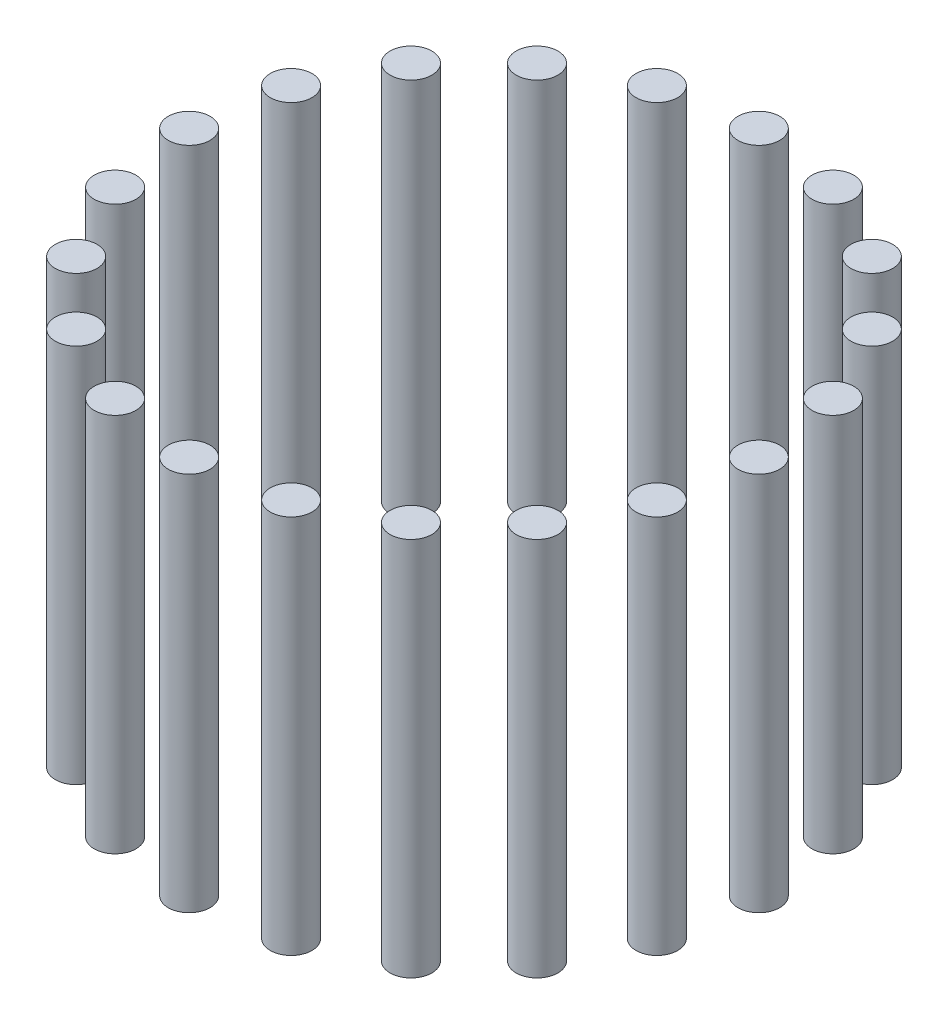
from build123d import *

# Parameters (mm, degrees)
SKETCH1_R              = 5.5
BOSS_EXTRUDE1_DEPTH    = 100
BOSS_EXTRUDE1_2_DEPTH  = 100
BOSS_EXTRUDE1_3_DEPTH  = 100
BOSS_EXTRUDE1_4_DEPTH  = 100
BOSS_EXTRUDE1_5_DEPTH  = 100
BOSS_EXTRUDE1_6_DEPTH  = 100
BOSS_EXTRUDE1_7_DEPTH  = 100
BOSS_EXTRUDE1_8_DEPTH  = 100
BOSS_EXTRUDE1_9_DEPTH  = 100
BOSS_EXTRUDE1_10_DEPTH = 100
BOSS_EXTRUDE1_11_DEPTH = 100
BOSS_EXTRUDE1_12_DEPTH = 100
BOSS_EXTRUDE1_13_DEPTH = 100
BOSS_EXTRUDE1_14_DEPTH = 100
BOSS_EXTRUDE1_15_DEPTH = 100
BOSS_EXTRUDE1_16_DEPTH = 100
BOSS_EXTRUDE1_17_DEPTH = 100
BOSS_EXTRUDE1_18_DEPTH = 100
BOSS_EXTRUDE1_19_DEPTH = 100
BOSS_EXTRUDE1_20_DEPTH = 100


with BuildPart() as part:
    # Sketch1 → Boss-Extrude1 (new body)
    with BuildSketch(Plane(origin=(0, 0, 0), x_dir=(1, 0, 0), z_dir=(0, 1, 0))):
        with Locations((0, 75)):
            Circle(SKETCH1_R)
    extrude(amount=BOSS_EXTRUDE1_DEPTH)


with BuildPart() as body_2:
    # Sketch1 → Boss-Extrude1 2 (new body)
    with BuildSketch(Plane(origin=(0, 0, 0), x_dir=(1, 0, 0), z_dir=(0, 1, 0))):
        with Locations((23.176274578, 71.329238722)):
            Circle(SKETCH1_R)
    extrude(amount=BOSS_EXTRUDE1_2_DEPTH)


with BuildPart() as body_3:
    # Sketch1 → Boss-Extrude1 3 (new body)
    with BuildSketch(Plane(origin=(0, 0, 0), x_dir=(1, 0, 0), z_dir=(0, 1, 0))):
        with Locations((44.083893922, 60.676274578)):
            Circle(SKETCH1_R)
    extrude(amount=BOSS_EXTRUDE1_3_DEPTH)


with BuildPart() as body_4:
    # Sketch1 → Boss-Extrude1 4 (new body)
    with BuildSketch(Plane(origin=(0, 0, 0), x_dir=(1, 0, 0), z_dir=(0, 1, 0))):
        with Locations((60.676274578, 44.083893922)):
            Circle(SKETCH1_R)
    extrude(amount=BOSS_EXTRUDE1_4_DEPTH)


with BuildPart() as body_5:
    # Sketch1 → Boss-Extrude1 5 (new body)
    with BuildSketch(Plane(origin=(0, 0, 0), x_dir=(1, 0, 0), z_dir=(0, 1, 0))):
        with Locations((71.329238722, 23.176274578)):
            Circle(SKETCH1_R)
    extrude(amount=BOSS_EXTRUDE1_5_DEPTH)


with BuildPart() as body_6:
    # Sketch1 → Boss-Extrude1 6 (new body)
    with BuildSketch(Plane(origin=(0, 0, 0), x_dir=(1, 0, 0), z_dir=(0, 1, 0))):
        with Locations((75, 0)):
            Circle(SKETCH1_R)
    extrude(amount=BOSS_EXTRUDE1_6_DEPTH)


with BuildPart() as body_7:
    # Sketch1 → Boss-Extrude1 7 (new body)
    with BuildSketch(Plane(origin=(0, 0, 0), x_dir=(1, 0, 0), z_dir=(0, 1, 0))):
        with Locations((71.329238722, -23.176274578)):
            Circle(SKETCH1_R)
    extrude(amount=BOSS_EXTRUDE1_7_DEPTH)


with BuildPart() as body_8:
    # Sketch1 → Boss-Extrude1 8 (new body)
    with BuildSketch(Plane(origin=(0, 0, 0), x_dir=(1, 0, 0), z_dir=(0, 1, 0))):
        with Locations((60.676274578, -44.083893922)):
            Circle(SKETCH1_R)
    extrude(amount=BOSS_EXTRUDE1_8_DEPTH)


with BuildPart() as body_9:
    # Sketch1 → Boss-Extrude1 9 (new body)
    with BuildSketch(Plane(origin=(0, 0, 0), x_dir=(1, 0, 0), z_dir=(0, 1, 0))):
        with Locations((44.083893922, -60.676274578)):
            Circle(SKETCH1_R)
    extrude(amount=BOSS_EXTRUDE1_9_DEPTH)


with BuildPart() as body_10:
    # Sketch1 → Boss-Extrude1 10 (new body)
    with BuildSketch(Plane(origin=(0, 0, 0), x_dir=(1, 0, 0), z_dir=(0, 1, 0))):
        with Locations((23.176274578, -71.329238722)):
            Circle(SKETCH1_R)
    extrude(amount=BOSS_EXTRUDE1_10_DEPTH)


with BuildPart() as body_11:
    # Sketch1 → Boss-Extrude1 11 (new body)
    with BuildSketch(Plane(origin=(0, 0, 0), x_dir=(1, 0, 0), z_dir=(0, 1, 0))):
        with Locations((0, -75)):
            Circle(SKETCH1_R)
    extrude(amount=BOSS_EXTRUDE1_11_DEPTH)


with BuildPart() as body_12:
    # Sketch1 → Boss-Extrude1 12 (new body)
    with BuildSketch(Plane(origin=(0, 0, 0), x_dir=(1, 0, 0), z_dir=(0, 1, 0))):
        with Locations((-23.176274578, -71.329238722)):
            Circle(SKETCH1_R)
    extrude(amount=BOSS_EXTRUDE1_12_DEPTH)


with BuildPart() as body_13:
    # Sketch1 → Boss-Extrude1 13 (new body)
    with BuildSketch(Plane(origin=(0, 0, 0), x_dir=(1, 0, 0), z_dir=(0, 1, 0))):
        with Locations((-44.083893922, -60.676274578)):
            Circle(SKETCH1_R)
    extrude(amount=BOSS_EXTRUDE1_13_DEPTH)


with BuildPart() as body_14:
    # Sketch1 → Boss-Extrude1 14 (new body)
    with BuildSketch(Plane(origin=(0, 0, 0), x_dir=(1, 0, 0), z_dir=(0, 1, 0))):
        with Locations((-60.676274578, -44.083893922)):
            Circle(SKETCH1_R)
    extrude(amount=BOSS_EXTRUDE1_14_DEPTH)


with BuildPart() as body_15:
    # Sketch1 → Boss-Extrude1 15 (new body)
    with BuildSketch(Plane(origin=(0, 0, 0), x_dir=(1, 0, 0), z_dir=(0, 1, 0))):
        with Locations((-71.329238722, -23.176274578)):
            Circle(SKETCH1_R)
    extrude(amount=BOSS_EXTRUDE1_15_DEPTH)


with BuildPart() as body_16:
    # Sketch1 → Boss-Extrude1 16 (new body)
    with BuildSketch(Plane(origin=(0, 0, 0), x_dir=(1, 0, 0), z_dir=(0, 1, 0))):
        with Locations((-75, 0)):
            Circle(SKETCH1_R)
    extrude(amount=BOSS_EXTRUDE1_16_DEPTH)


with BuildPart() as body_17:
    # Sketch1 → Boss-Extrude1 17 (new body)
    with BuildSketch(Plane(origin=(0, 0, 0), x_dir=(1, 0, 0), z_dir=(0, 1, 0))):
        with Locations((-71.329238722, 23.176274578)):
            Circle(SKETCH1_R)
    extrude(amount=BOSS_EXTRUDE1_17_DEPTH)


with BuildPart() as body_18:
    # Sketch1 → Boss-Extrude1 18 (new body)
    with BuildSketch(Plane(origin=(0, 0, 0), x_dir=(1, 0, 0), z_dir=(0, 1, 0))):
        with Locations((-60.676274578, 44.083893922)):
            Circle(SKETCH1_R)
    extrude(amount=BOSS_EXTRUDE1_18_DEPTH)


with BuildPart() as body_19:
    # Sketch1 → Boss-Extrude1 19 (new body)
    with BuildSketch(Plane(origin=(0, 0, 0), x_dir=(1, 0, 0), z_dir=(0, 1, 0))):
        with Locations((-44.083893922, 60.676274578)):
            Circle(SKETCH1_R)
    extrude(amount=BOSS_EXTRUDE1_19_DEPTH)


with BuildPart() as body_20:
    # Sketch1 → Boss-Extrude1 20 (new body)
    with BuildSketch(Plane(origin=(0, 0, 0), x_dir=(1, 0, 0), z_dir=(0, 1, 0))):
        with Locations((-23.176274578, 71.329238722)):
            Circle(SKETCH1_R)
    extrude(amount=BOSS_EXTRUDE1_20_DEPTH)


solid = Compound([part.part, body_2.part, body_3.part, body_4.part, body_5.part, body_6.part, body_7.part, body_8.part, body_9.part, body_10.part, body_11.part, body_12.part, body_13.part, body_14.part, body_15.part, body_16.part, body_17.part, body_18.part, body_19.part, body_20.part])
